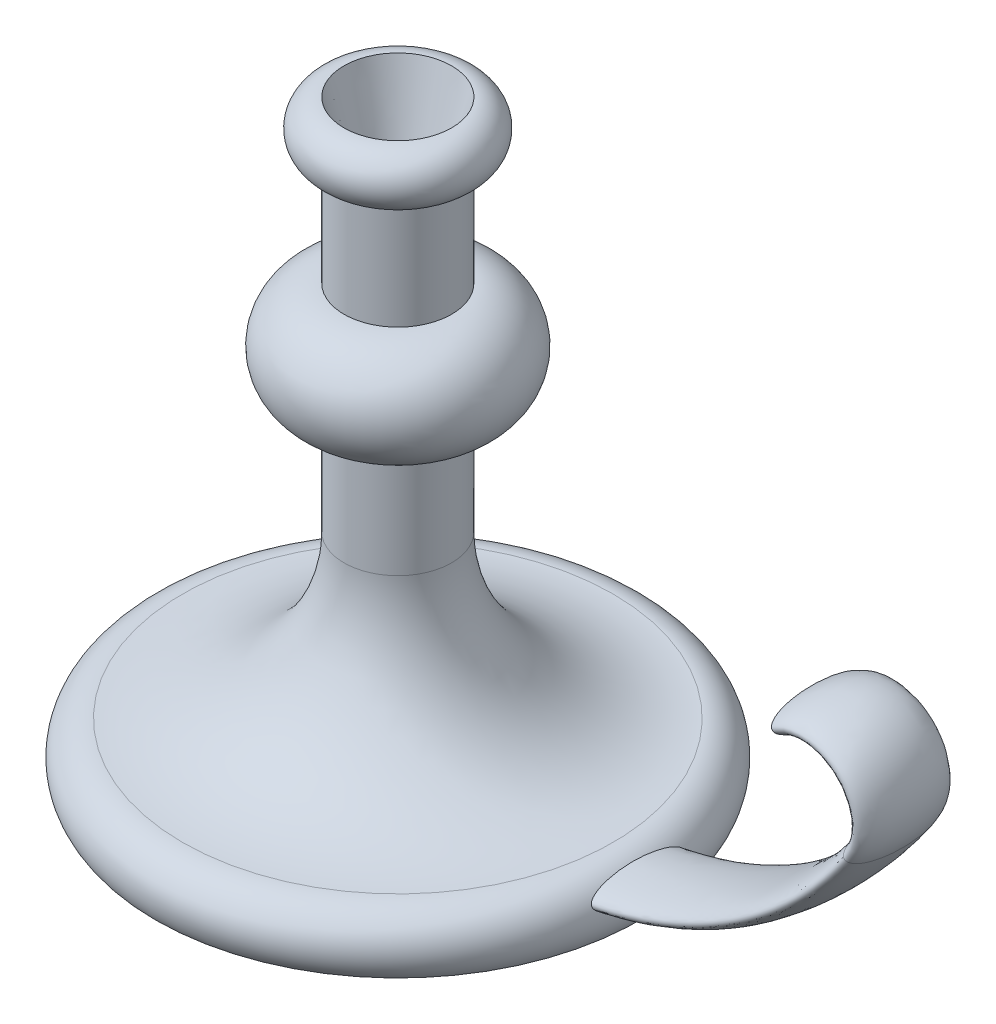
from build123d import *

# Parameters (mm, degrees)
SKETCH2_RX         = 17.5
SKETCH2_RY         = 5
SKETCH4_R          = 20
CUT_EXTRUDE1_DEPTH = 25
CUT_EXTRUDE1_TAPER = 15


with BuildPart() as part:
    # Sketch1 → Revolve1 (revolve)
    with BuildSketch(Plane.XY):
        with BuildLine():
            Line((0, 0), (0, 220))
            Line((0, 220), (20, 220))
            ThreePointArc((20, 220), (30, 210), (20, 200))
            Line((20, 200), (20, 160))
            ThreePointArc((20, 160), (40, 140), (20, 120))
            Line((20, 120), (20, 80))
            ThreePointArc((20, 80), (37.573593129, 37.573593129), (80, 20))
            ThreePointArc((80, 20), (91.180339887, 13.090169944), (90, 0))
            Line((90, 0), (0, 0))
        make_face()
    revolve(axis=Axis((0, 0, 0), (0, 1, 0)))

    # Sweep1: sweep along a path in Sketch3
    with BuildLine(Plane.XY) as sweep1_path:
        Line((0, 10), (60, 10))
        ThreePointArc((60, 10), (129.821200219, 27.240819526), (183.592070943, 75))
        ThreePointArc((183.592070943, 75), (181.589459557, 100.13318221), (156.580798093, 103.335392725))
    # Sketch2 → Sweep1 (sweep)
    with BuildSketch(Plane(origin=(0, 0, 0), x_dir=(0, 0, -1), z_dir=(1, 0, 0))):
        with Locations((0, 10)):
            Ellipse(SKETCH2_RX, SKETCH2_RY)
    sweep(path=sweep1_path.line)

    # Sketch4 → Cut-Extrude1 (cut)
    with BuildSketch(Plane(origin=(0, 220, 0), x_dir=(1, 0, 0), z_dir=(0, 1, 0))):
        Circle(SKETCH4_R)
    extrude(amount=-CUT_EXTRUDE1_DEPTH, taper=CUT_EXTRUDE1_TAPER, mode=Mode.SUBTRACT)


solid = part.part
